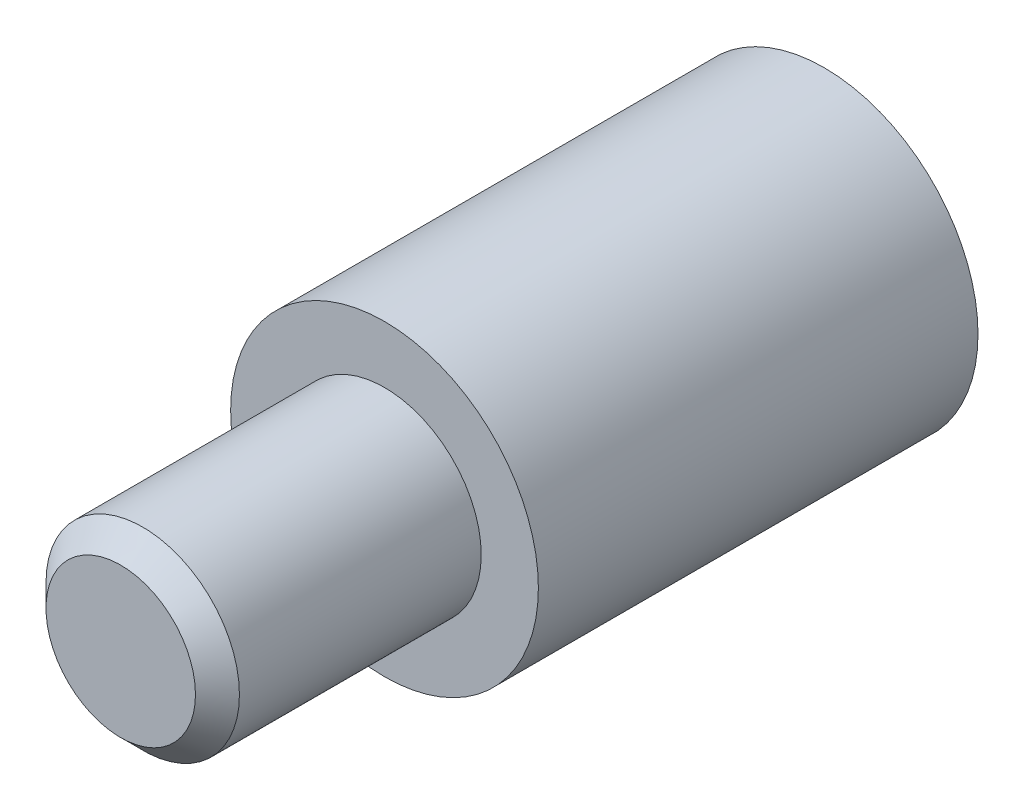
from build123d import *

# Parameters (mm, degrees)
SKETCH1_R           = 3.5
BOSS_EXTRUDE1_DEPTH = 7
SKETCH2_R           = 3.5
SKETCH2_R_2         = 2
BOSS_EXTRUDE2_DEPTH = 3
SKETCH3_R           = 2.2
BOSS_EXTRUDE3_DEPTH = 6
CHAMFER1_SIZE       = 0.5


with BuildPart() as part:
    # Sketch1 → Boss-Extrude1 (new body)
    with BuildSketch(Plane(origin=(0, 0, 107.93542322), x_dir=(-1, 0, 0), z_dir=(0, 0, -1))):
        with Locations((-59.79735108, 58.015798494)):
            Circle(SKETCH1_R)
    extrude(amount=BOSS_EXTRUDE1_DEPTH)

    # Sketch2 → Boss-Extrude2 (add)
    with BuildSketch(Plane(origin=(0, 0, 100.93542322), x_dir=(-1, 0, 0), z_dir=(0, 0, -1))):
        with Locations((-59.79735108, 58.015798494)):
            Circle(SKETCH2_R)
        with Locations((-59.79735108, 58.015798494)):
            Circle(SKETCH2_R_2, mode=Mode.SUBTRACT)
    extrude(amount=BOSS_EXTRUDE2_DEPTH)

    # Sketch3 → Boss-Extrude3 (add)
    with BuildSketch(Plane.XY.offset(107.93542322)):
        with Locations((59.79735108, 58.015798494)):
            Circle(SKETCH3_R)
    extrude(amount=BOSS_EXTRUDE3_DEPTH)

    # Chamfer1
    chamfer1_edges = [part.edges().sort_by_distance(p)[0] for p in [
        (57.59735108, 58.015798494, 113.93542322),
    ]]
    chamfer(chamfer1_edges, length=CHAMFER1_SIZE)


solid = part.part
